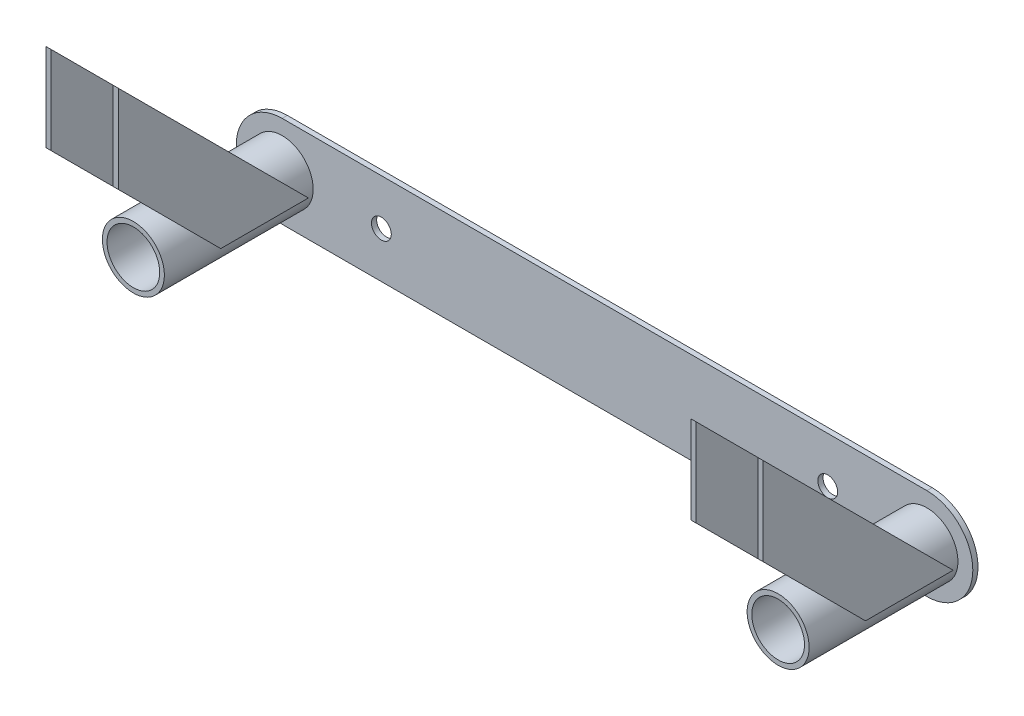
from build123d import *

# Parameters (mm, degrees)
SKETCH1_R           = 15.875
SKETCH1_R_2         = 13.49375
PIPE_BASE_DEPTH     = 76.2
PIPE_BASE_2_DEPTH   = 76.2
SKETCH1_3_R         = 15.875
SKETCH1_3_R_2       = 13.49375
SKETCH1_3_R_3       = 5.08
BASE_PLATE_DEPTH    = 2.6543
SKETCH1_4_R         = 5.08
CASTER_HOLES_DEPTH  = 2.6543
PLATE_SUPPORT_DEPTH = 2.6543


with BuildPart() as part:
    # Sketch1 → Pipe Base (new body)
    with BuildSketch(Plane.XY):
        with Locations((-165.1, 0)):
            Circle(SKETCH1_R)
        with Locations((-165.1, 0)):
            Circle(SKETCH1_R_2, mode=Mode.SUBTRACT)
    extrude(amount=PIPE_BASE_DEPTH)


with BuildPart() as body_2:
    # Sketch1 → Pipe Base 2 (new body)
    with BuildSketch(Plane.XY):
        with Locations((165.1, 0)):
            Circle(SKETCH1_R)
        with Locations((165.1, 0)):
            Circle(SKETCH1_R_2, mode=Mode.SUBTRACT)
    extrude(amount=PIPE_BASE_2_DEPTH)


with BuildPart() as body_3:
    # Sketch1_3 → Base Plate (new body)
    with BuildSketch(Plane.XY):
        with BuildLine():
            ThreePointArc((165.1, 23.495), (188.595, 0), (165.1, -23.495))
            Line((165.1, -23.495), (-165.1, -23.495))
            ThreePointArc((-165.1, -23.495), (-188.595, 0), (-165.1, 23.495))
            Line((-165.1, 23.495), (165.1, 23.495))
        make_face()
        with Locations((-165.1, 0)):
            Circle(SKETCH1_3_R, mode=Mode.SUBTRACT)
        with Locations((165.1, 0)):
            Circle(SKETCH1_3_R, mode=Mode.SUBTRACT)
        with Locations((-165.1, 0)):
            Circle(SKETCH1_3_R)
        with Locations((-165.1, 0)):
            Circle(SKETCH1_3_R_2, mode=Mode.SUBTRACT)
        with Locations((-165.1, 0)):
            Circle(SKETCH1_3_R_2)
        with Locations((165.1, 0)):
            Circle(SKETCH1_3_R)
        with Locations((165.1, 0)):
            Circle(SKETCH1_3_R_2, mode=Mode.SUBTRACT)
        with Locations((165.1, 0)):
            Circle(SKETCH1_3_R_2)
        with Locations((-114.3, 0)):
            Circle(SKETCH1_3_R_3)
        with Locations((114.3, 0)):
            Circle(SKETCH1_3_R_3)
    extrude(amount=-BASE_PLATE_DEPTH)

    # Sketch1_4 → Caster Holes (cut)
    with BuildSketch(Plane.XY):
        with Locations((114.3, 0)):
            Circle(SKETCH1_4_R)
        with Locations((-114.3, 0)):
            Circle(SKETCH1_4_R)
    extrude(amount=-CASTER_HOLES_DEPTH, mode=Mode.SUBTRACT)


with BuildPart() as body_4:
    # Sketch2 → Plate Support (new body)
    with BuildSketch(Plane.ZY.offset(180.975)):
        Polygon((5.08, 0), (49.981280605, 0), (102.418719395, 52.437438789), (102.418719395, 97.338719395), align=None)
    extrude(amount=PLATE_SUPPORT_DEPTH)


with BuildPart() as body_5:
    # Plate Support Left Mirror: mirrored copy
    add(body_4.part.mirror(Plane.ZY.offset(165.1)))


with BuildPart() as body_6:
    # Plate Support Mirror: mirrored copy
    add(body_5.part.mirror(Plane(origin=(0, 0, 0), x_dir=(0, 0, 1), z_dir=(1, 0, 0))))


with BuildPart() as body_7:
    # Plate Support Mirror 2: mirrored copy
    add(body_4.part.mirror(Plane(origin=(0, 0, 0), x_dir=(0, 0, 1), z_dir=(1, 0, 0))))


solid = Compound([part.part, body_2.part, body_3.part, body_4.part, body_5.part, body_6.part, body_7.part])
